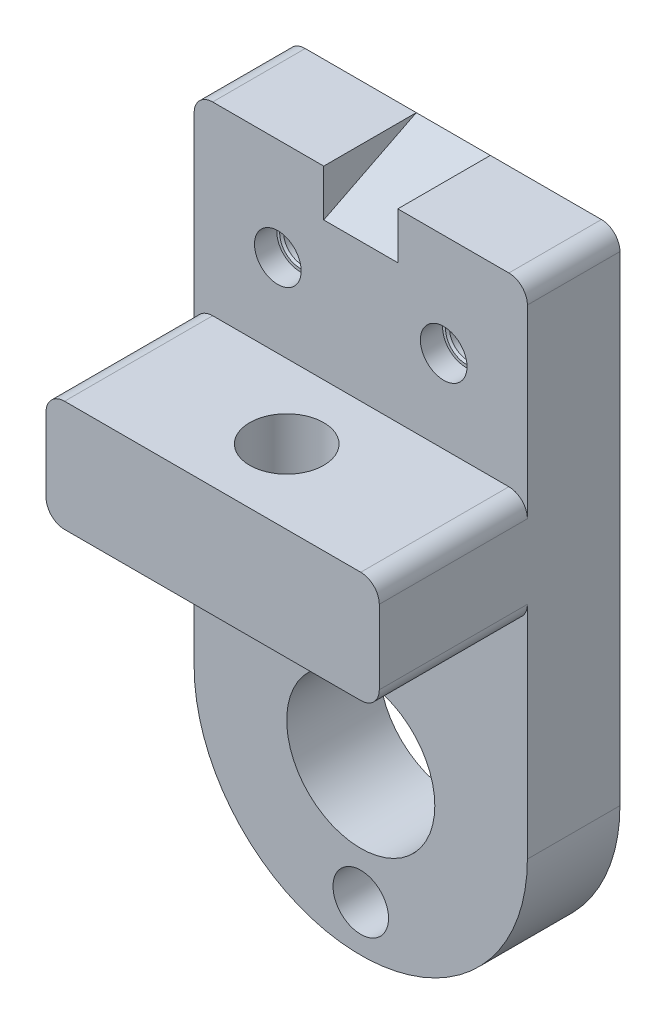
from build123d import *

# Parameters (mm, degrees)
SALIENTE_EXTRUIR1_DEPTH                     = 31.75
CROQUIS1_R                                  = 9.525
CROQUIS1_R_2                                = 25.4
SALIENTE_EXTRUIR1_2_DEPTH                   = 31.75
SALIENTE_EXTRUIR2_DEPTH                     = 82.55
SALIENTE_EXTRUIR3_REACH                     = 204.274
TALADRO1_D                                  = 25.4
REFRENTADO_PARA_TORNILLO_CON_CABEZA_2_COUNT = 2
REFRENTADO_PARA_TORNILLO_CON_CABEZA_2_PITCH = 56.896
REFRENTADO_PARA_TORNILLO_CON_CABEZA_3_COUNT = 2
REFRENTADO_PARA_TORNILLO_CON_CABEZA_3_PITCH = 110.426919924


with BuildPart() as part:
    # Croquis1 → Saliente-Extruir1 (new body)
    with BuildSketch(Plane.XY):
        with BuildLine():
            Line((50.8, 170.942), (12.7, 170.942))
            Line((12.7, 170.942), (12.7, 154.94))
            Line((12.7, 154.94), (-12.7, 154.94))
            Line((-12.7, 154.94), (-12.7, 170.942))
            Line((-12.7, 170.942), (-50.8, 170.942))
            ThreePointArc((-50.8, 170.942), (-55.290128061, 169.082128061), (-57.15, 164.592))
            Line((-57.15, 164.592), (-57.15, 101.092))
            ThreePointArc((-57.15, 101.092), (-55.290128061, 105.582128061), (-50.8, 107.442))
            Line((-50.8, 107.442), (50.8, 107.442))
            ThreePointArc((50.8, 107.442), (55.290128061, 105.582128061), (57.15, 101.092))
            Line((57.15, 101.092), (57.15, 164.592))
            ThreePointArc((57.15, 164.592), (55.290128061, 169.082128061), (50.8, 170.942))
        make_face()
    extrude(amount=SALIENTE_EXTRUIR1_DEPTH)



with BuildPart() as body_2:
    # Croquis1 → Saliente-Extruir1 2 (new body)
    with BuildSketch(Plane.XY):
        with BuildLine():
            Line((57.15, 0), (57.15, 75.692))
            ThreePointArc((57.15, 75.692), (55.290128061, 71.201871939), (50.8, 69.342))
            Line((50.8, 69.342), (-50.8, 69.342))
            ThreePointArc((-50.8, 69.342), (-55.290128061, 71.201871939), (-57.15, 75.692))
            Line((-57.15, 75.692), (-57.15, 0))
            ThreePointArc((-57.15, 0), (0, -57.15), (57.15, 0))
        make_face()
        with Locations((0, -41.402)):
            Circle(CROQUIS1_R, mode=Mode.SUBTRACT)
        Circle(CROQUIS1_R_2, mode=Mode.SUBTRACT)
    extrude(amount=SALIENTE_EXTRUIR1_2_DEPTH)


with BuildPart() as part_1:
    add(part.part)

    add(body_2.part)  # Saliente-Extruir2 merges body 2
    # Croquis1_3 → Saliente-Extruir2 (add)
    with BuildSketch(Plane.XY):
        with BuildLine():
            Line((57.15, 75.692), (57.15, 101.092))
            ThreePointArc((57.15, 101.092), (55.290128061, 105.582128061), (50.8, 107.442))
            Line((50.8, 107.442), (-50.8, 107.442))
            ThreePointArc((-50.8, 107.442), (-55.290128061, 105.582128061), (-57.15, 101.092))
            Line((-57.15, 101.092), (-57.15, 75.692))
            ThreePointArc((-57.15, 75.692), (-55.290128061, 71.201871939), (-50.8, 69.342))
            Line((-50.8, 69.342), (50.8, 69.342))
            ThreePointArc((50.8, 69.342), (55.290128061, 71.201871939), (57.15, 75.692))
        make_face()
    extrude(amount=SALIENTE_EXTRUIR2_DEPTH)

    # Croquis4 → Saliente-Extruir3 (add, up to next)
    with BuildSketch(Plane.ZY.offset(-12.7), mode=Mode.PRIVATE) as saliente_extruir3_sk1:
        Polygon((31.75, 154.94), (0, 170.942), (0, 154.94), align=None)
    saliente_extruir3_tool1 = extrude(saliente_extruir3_sk1.sketch, amount=SALIENTE_EXTRUIR3_REACH, mode=Mode.PRIVATE) - part_1.part
    add(saliente_extruir3_tool1.solids().sort_by_distance((12.7, 160.274, 10.583333))[0])

    # Taladro1 (through all)
    with Locations(Plane(origin=(0, 107.442, 0), x_dir=(1, 0, 0), z_dir=(0, 1, 0))):
        with Locations((0, -57.15)):
            Hole(TALADRO1_D / 2)

    # Croquis10 → Refrentado para tornillo con cabeza troncocónica de #01 (revolve, cut)
    with BuildSketch(Plane(origin=(28.448, 135.89, 31.75), x_dir=(0, -1, 0), z_dir=(1, 0, 0))):
        Polygon((0, 0), (0, 31.75), (6.35, 31.75), (6.35, 8.350483939), (6.985, 7.62), (8.001, 7.62), (8.001, 0), align=None)
    refrentado_para_tornillo_con_cabeza_tron = revolve(axis=Axis((28.448, 135.89, 38.1), (0, 0, -1)), mode=Mode.SUBTRACT)

    # Refrentado para tornillo con cabeza  2: Refrentado para tornillo con cabeza troncocónica de #01 ×2
    with Locations(*[(-i * REFRENTADO_PARA_TORNILLO_CON_CABEZA_2_PITCH, 0, 0) for i in range(1, REFRENTADO_PARA_TORNILLO_CON_CABEZA_2_COUNT)]):
        add(refrentado_para_tornillo_con_cabeza_tron, mode=Mode.SUBTRACT)

    # Refrentado para tornillo con cabeza  3: Refrentado para tornillo con cabeza troncocónica de #01 ×2
    with Locations(*[Vector(-0.5175368473475671, -0.8556609209479776, 0) * (i * REFRENTADO_PARA_TORNILLO_CON_CABEZA_3_PITCH) for i in range(1, REFRENTADO_PARA_TORNILLO_CON_CABEZA_3_COUNT)]):
        add(refrentado_para_tornillo_con_cabeza_tron, mode=Mode.SUBTRACT)


solid = part_1.part
